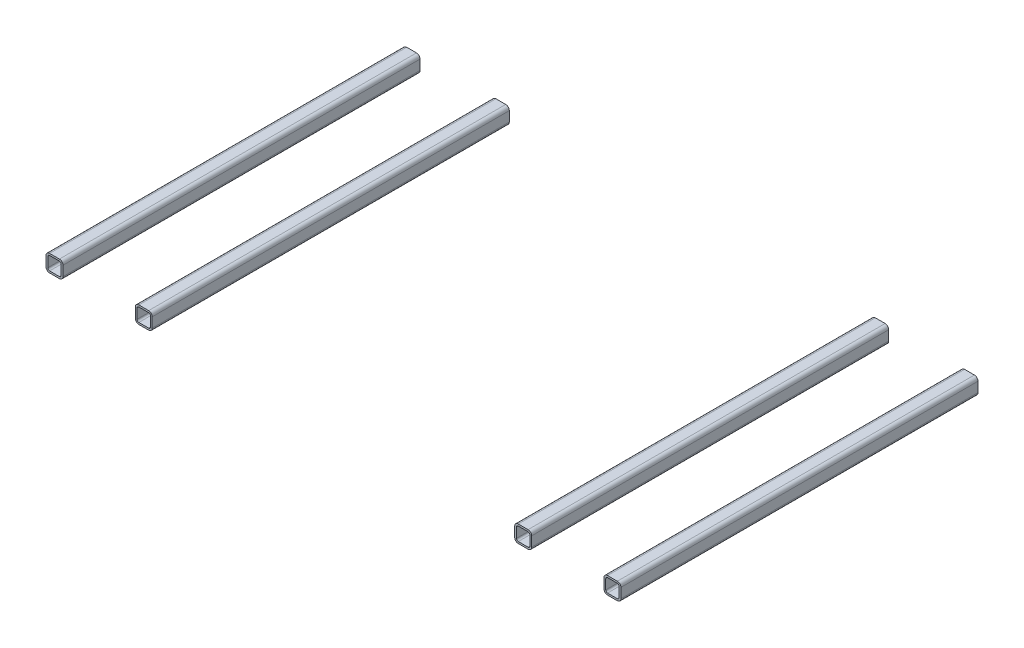
from build123d import *

# Parameters (mm, degrees)
SQUARE_TUBE_20_X_20_X_2_2_DEPTH   = 400
SQUARE_TUBE_20_X_20_X_2_2_2_DEPTH = 400
SQUARE_TUBE_20_X_20_X_2_2_3_DEPTH = 400
SQUARE_TUBE_20_X_20_X_2_2_4_DEPTH = 400


with BuildPart() as part:
    # Sketch12 → Square tube 20 X 20 X 2(2) (new body)
    with BuildSketch(Plane(origin=(-312.5, 0, 200), x_dir=(-1, 0, 0), z_dir=(0, 0, -1))):
        with BuildLine():
            Line((-5.5, -9.5), (5.5, -9.5))
            ThreePointArc((5.5, -9.5), (8.328427125, -8.328427125), (9.5, -5.5))
            Line((9.5, -5.5), (9.5, 5.5))
            ThreePointArc((9.5, 5.5), (8.328427125, 8.328427125), (5.5, 9.5))
            Line((5.5, 9.5), (-5.5, 9.5))
            ThreePointArc((-5.5, 9.5), (-8.328427125, 8.328427125), (-9.5, 5.5))
            Line((-9.5, 5.5), (-9.5, -5.5))
            ThreePointArc((-9.5, -5.5), (-8.328427125, -8.328427125), (-5.5, -9.5))
        make_face()
        with BuildLine():
            Line((-5.5, -7.5), (5.5, -7.5))
            ThreePointArc((5.5, -7.5), (6.914213562, -6.914213562), (7.5, -5.5))
            Line((7.5, -5.5), (7.5, 5.5))
            ThreePointArc((7.5, 5.5), (6.914213562, 6.914213562), (5.5, 7.5))
            Line((5.5, 7.5), (-5.5, 7.5))
            ThreePointArc((-5.5, 7.5), (-6.914213562, 6.914213562), (-7.5, 5.5))
            Line((-7.5, 5.5), (-7.5, -5.5))
            ThreePointArc((-7.5, -5.5), (-6.914213562, -6.914213562), (-5.5, -7.5))
        make_face(mode=Mode.SUBTRACT)
    extrude(amount=SQUARE_TUBE_20_X_20_X_2_2_DEPTH)


with BuildPart() as body_2:
    # Sketch12 on segment 2 (carried to segment 2) → Square tube 20 X 20 X 2_2 2 (new body)
    with BuildSketch(Plane(origin=(-212.5, 0, 200), x_dir=(-1, 0, 0), z_dir=(0, 0, -1))):
        with BuildLine():
            Line((-5.5, -9.5), (5.5, -9.5))
            ThreePointArc((5.5, -9.5), (8.328427125, -8.328427125), (9.5, -5.5))
            Line((9.5, -5.5), (9.5, 5.5))
            ThreePointArc((9.5, 5.5), (8.328427125, 8.328427125), (5.5, 9.5))
            Line((5.5, 9.5), (-5.5, 9.5))
            ThreePointArc((-5.5, 9.5), (-8.328427125, 8.328427125), (-9.5, 5.5))
            Line((-9.5, 5.5), (-9.5, -5.5))
            ThreePointArc((-9.5, -5.5), (-8.328427125, -8.328427125), (-5.5, -9.5))
        make_face()
        with BuildLine():
            Line((-5.5, -7.5), (5.5, -7.5))
            ThreePointArc((5.5, -7.5), (6.914213562, -6.914213562), (7.5, -5.5))
            Line((7.5, -5.5), (7.5, 5.5))
            ThreePointArc((7.5, 5.5), (6.914213562, 6.914213562), (5.5, 7.5))
            Line((5.5, 7.5), (-5.5, 7.5))
            ThreePointArc((-5.5, 7.5), (-6.914213562, 6.914213562), (-7.5, 5.5))
            Line((-7.5, 5.5), (-7.5, -5.5))
            ThreePointArc((-7.5, -5.5), (-6.914213562, -6.914213562), (-5.5, -7.5))
        make_face(mode=Mode.SUBTRACT)
    extrude(amount=SQUARE_TUBE_20_X_20_X_2_2_2_DEPTH)


with BuildPart() as body_3:
    # Sketch12 on segment 3 (carried to segment 3) → Square tube 20 X 20 X 2_2 3 (new body)
    with BuildSketch(Plane(origin=(212.5, 0, 200), x_dir=(-1, 0, 0), z_dir=(0, 0, -1))):
        with BuildLine():
            Line((-5.5, -9.5), (5.5, -9.5))
            ThreePointArc((5.5, -9.5), (8.328427125, -8.328427125), (9.5, -5.5))
            Line((9.5, -5.5), (9.5, 5.5))
            ThreePointArc((9.5, 5.5), (8.328427125, 8.328427125), (5.5, 9.5))
            Line((5.5, 9.5), (-5.5, 9.5))
            ThreePointArc((-5.5, 9.5), (-8.328427125, 8.328427125), (-9.5, 5.5))
            Line((-9.5, 5.5), (-9.5, -5.5))
            ThreePointArc((-9.5, -5.5), (-8.328427125, -8.328427125), (-5.5, -9.5))
        make_face()
        with BuildLine():
            Line((-5.5, -7.5), (5.5, -7.5))
            ThreePointArc((5.5, -7.5), (6.914213562, -6.914213562), (7.5, -5.5))
            Line((7.5, -5.5), (7.5, 5.5))
            ThreePointArc((7.5, 5.5), (6.914213562, 6.914213562), (5.5, 7.5))
            Line((5.5, 7.5), (-5.5, 7.5))
            ThreePointArc((-5.5, 7.5), (-6.914213562, 6.914213562), (-7.5, 5.5))
            Line((-7.5, 5.5), (-7.5, -5.5))
            ThreePointArc((-7.5, -5.5), (-6.914213562, -6.914213562), (-5.5, -7.5))
        make_face(mode=Mode.SUBTRACT)
    extrude(amount=SQUARE_TUBE_20_X_20_X_2_2_3_DEPTH)


with BuildPart() as body_4:
    # Sketch12 on segment 4 (carried to segment 4) → Square tube 20 X 20 X 2_2 4 (new body)
    with BuildSketch(Plane(origin=(312.5, 0, 200), x_dir=(-1, 0, 0), z_dir=(0, 0, -1))):
        with BuildLine():
            Line((-5.5, -9.5), (5.5, -9.5))
            ThreePointArc((5.5, -9.5), (8.328427125, -8.328427125), (9.5, -5.5))
            Line((9.5, -5.5), (9.5, 5.5))
            ThreePointArc((9.5, 5.5), (8.328427125, 8.328427125), (5.5, 9.5))
            Line((5.5, 9.5), (-5.5, 9.5))
            ThreePointArc((-5.5, 9.5), (-8.328427125, 8.328427125), (-9.5, 5.5))
            Line((-9.5, 5.5), (-9.5, -5.5))
            ThreePointArc((-9.5, -5.5), (-8.328427125, -8.328427125), (-5.5, -9.5))
        make_face()
        with BuildLine():
            Line((-5.5, -7.5), (5.5, -7.5))
            ThreePointArc((5.5, -7.5), (6.914213562, -6.914213562), (7.5, -5.5))
            Line((7.5, -5.5), (7.5, 5.5))
            ThreePointArc((7.5, 5.5), (6.914213562, 6.914213562), (5.5, 7.5))
            Line((5.5, 7.5), (-5.5, 7.5))
            ThreePointArc((-5.5, 7.5), (-6.914213562, 6.914213562), (-7.5, 5.5))
            Line((-7.5, 5.5), (-7.5, -5.5))
            ThreePointArc((-7.5, -5.5), (-6.914213562, -6.914213562), (-5.5, -7.5))
        make_face(mode=Mode.SUBTRACT)
    extrude(amount=SQUARE_TUBE_20_X_20_X_2_2_4_DEPTH)


solid = Compound([part.part, body_2.part, body_3.part, body_4.part])
